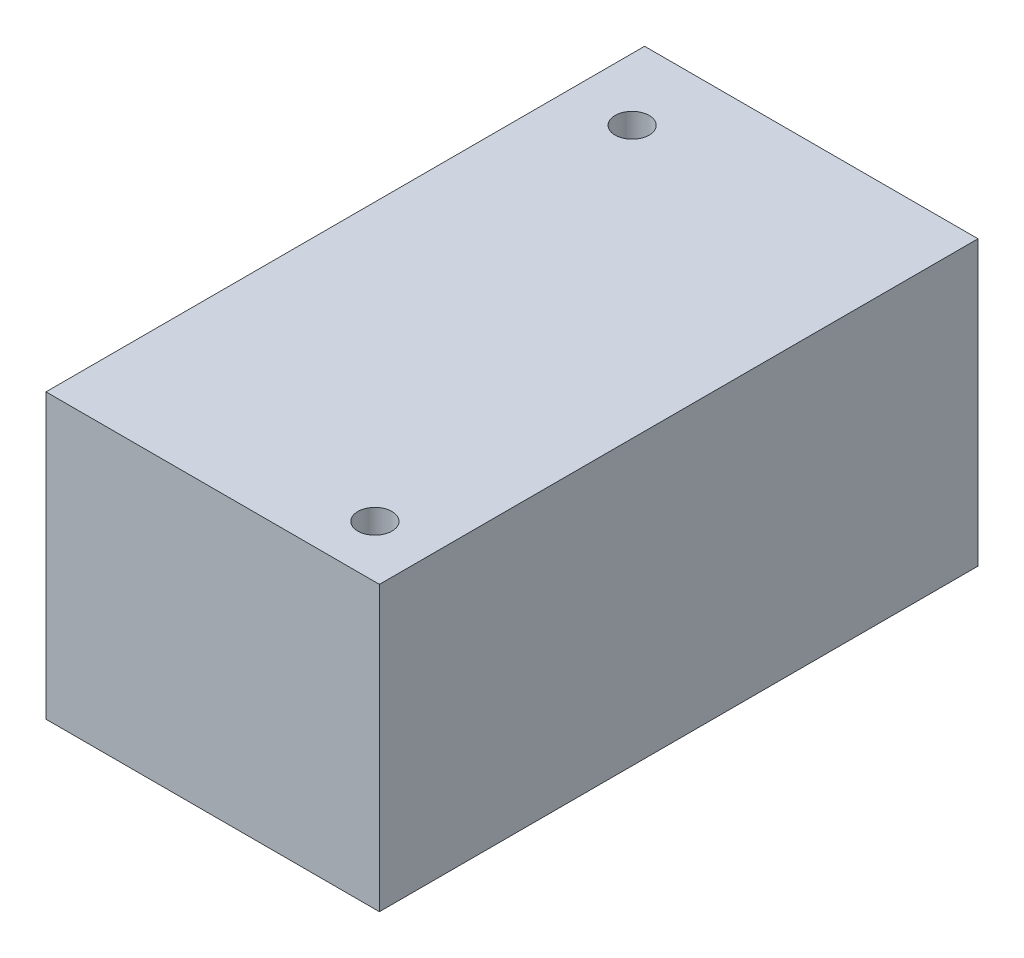
from build123d import *

# Parameters (mm, degrees)
SKETCH1_W           = 127
SKETCH1_H           = 90
BOSS_EXTRUDE1_DEPTH = 228
SKETCH2_R           = 6.5
CUT_EXTRUDE1_DEPTH  = 228
SKETCH3_W           = 127
SKETCH3_H           = 228
SKETCH3_R           = 6.5
BOSS_EXTRUDE2_DEPTH = 18


with BuildPart() as part:
    # Sketch1 → Boss-Extrude1 (new body)
    with BuildSketch(Plane.XY):
        Rectangle(SKETCH1_W, SKETCH1_H)
    extrude(amount=BOSS_EXTRUDE1_DEPTH)

    # Sketch2 → Cut-Extrude1 (cut)
    with BuildSketch(Plane(origin=(0, 45, 0), x_dir=(1, 0, 0), z_dir=(0, 1, 0))):
        with Locations((-39.802347905, -28.441961554)):
            Circle(SKETCH2_R)
        with Locations((41.843493952, -208.06281364)):
            Circle(SKETCH2_R)
    extrude(amount=-CUT_EXTRUDE1_DEPTH, mode=Mode.SUBTRACT)

    # Sketch3 → Boss-Extrude2 (add)
    with BuildSketch(Plane(origin=(0, 45, 0), x_dir=(1, 0, 0), z_dir=(0, 1, 0))):
        with Locations((0, -114)):
            Rectangle(SKETCH3_W, SKETCH3_H)
        with Locations((-39.802347905, -28.441961554)):
            Circle(SKETCH3_R, mode=Mode.SUBTRACT)
        with Locations((41.843493952, -208.06281364)):
            Circle(SKETCH3_R, mode=Mode.SUBTRACT)
    extrude(amount=BOSS_EXTRUDE2_DEPTH)


solid = part.part
